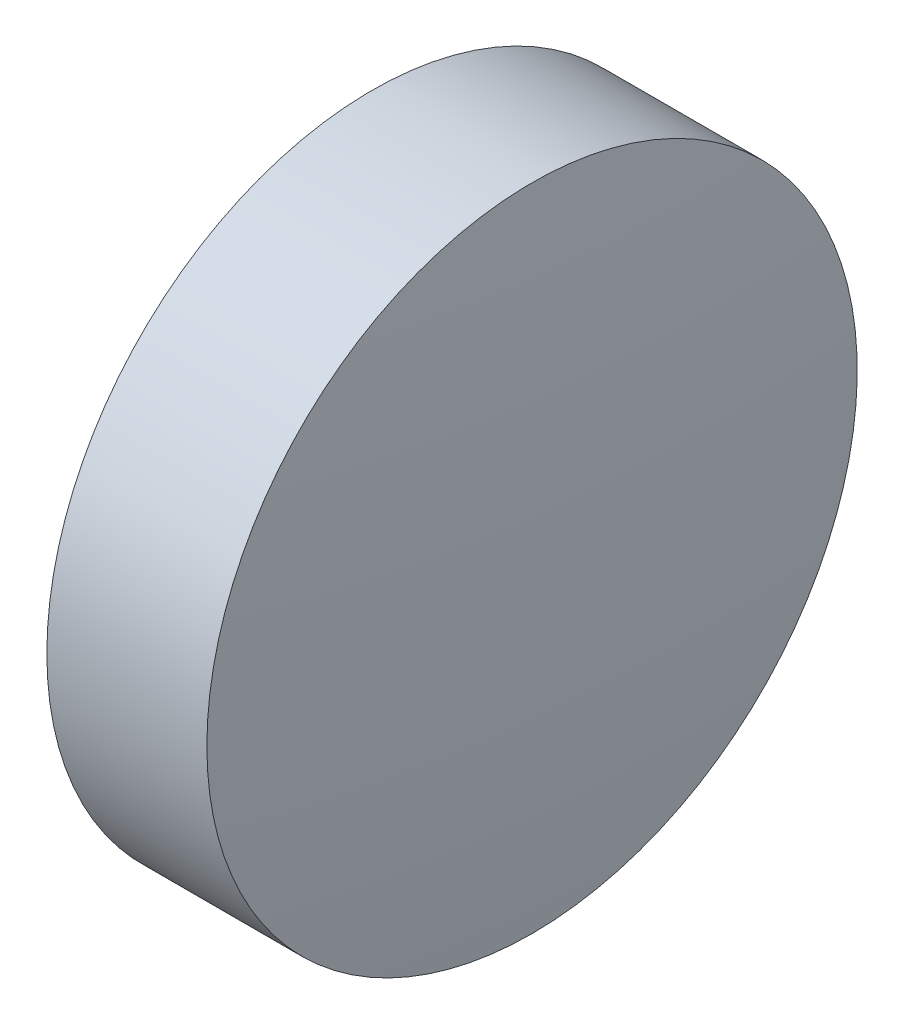
from build123d import *


with BuildPart() as part:
    # 草图1 → 旋转1 (revolve)
    with BuildSketch(Plane.XY, mode=Mode.PRIVATE) as revolve_1_sk:
        with BuildLine():
            Line((485.828902489, 224.662621286), (485.828902489, 227.812621286))
            Line((485.828902489, 227.812621286), (487.378902489, 227.812621286))
            ThreePointArc((487.378902489, 227.812621286), (487.491381254, 226.23940599), (487.528902489, 224.662621286))
            Line((487.528902489, 224.662621286), (485.828902489, 224.662621286))
        make_face()
    revolve(revolve_1_sk.sketch.rotate(Axis((484.967274319, 224.662621286, 0), (1, 0, 0)), 180), axis=Axis((484.967274319, 224.662621286, 0), (1, 0, 0)))  # turned: the seam where the file's is


solid = part.part
